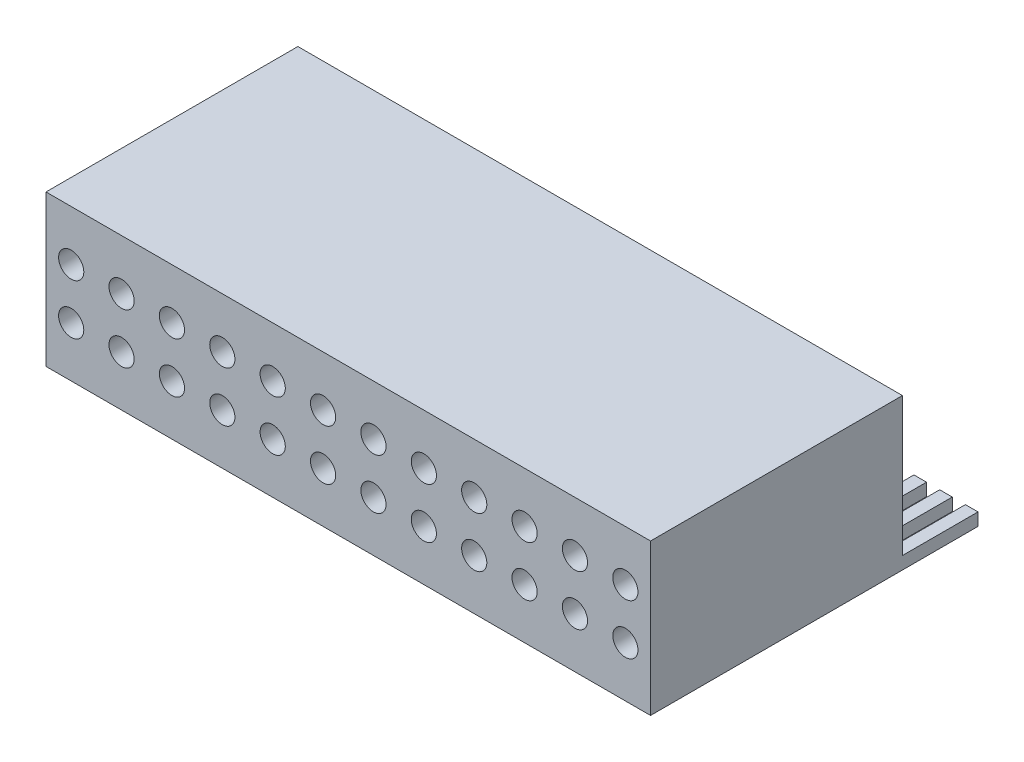
from build123d import *

# Parameters (mm, degrees)
SKETCH2_W           = 24
SKETCH2_H           = 6
BOSS_EXTRUDE1_DEPTH = 10
SKETCH3_R           = 0.5
CUT_EXTRUDE1_DEPTH  = 5
SKETCH4_W           = 0.5
SKETCH4_H           = 3
BOSS_EXTRUDE2_DEPTH = 0.5


with BuildPart() as part:
    # Sketch2 → Boss-Extrude1 (new body)
    with BuildSketch(Plane.XY):
        with Locations((12, 3)):
            Rectangle(SKETCH2_W, SKETCH2_H)
    extrude(amount=BOSS_EXTRUDE1_DEPTH)

    # Sketch3 → Cut-Extrude1 (cut)
    with BuildSketch(Plane.XY.offset(10)):
        with Locations((1, 2)):
            Circle(SKETCH3_R)
        with Locations((3, 2)):
            Circle(SKETCH3_R)
        with Locations((5, 2)):
            Circle(SKETCH3_R)
        with Locations((7, 2)):
            Circle(SKETCH3_R)
        with Locations((9, 2)):
            Circle(SKETCH3_R)
        with Locations((11, 2)):
            Circle(SKETCH3_R)
        with Locations((13, 2)):
            Circle(SKETCH3_R)
        with Locations((15, 2)):
            Circle(SKETCH3_R)
        with Locations((17, 2)):
            Circle(SKETCH3_R)
        with Locations((19, 2)):
            Circle(SKETCH3_R)
        with Locations((21, 2)):
            Circle(SKETCH3_R)
        with Locations((23, 2)):
            Circle(SKETCH3_R)
        with Locations((23, 4)):
            Circle(SKETCH3_R)
        with Locations((21, 4)):
            Circle(SKETCH3_R)
        with Locations((19, 4)):
            Circle(SKETCH3_R)
        with Locations((17, 4)):
            Circle(SKETCH3_R)
        with Locations((15, 4)):
            Circle(SKETCH3_R)
        with Locations((13, 4)):
            Circle(SKETCH3_R)
        with Locations((11, 4)):
            Circle(SKETCH3_R)
        with Locations((9, 4)):
            Circle(SKETCH3_R)
        with Locations((7, 4)):
            Circle(SKETCH3_R)
        with Locations((5, 4)):
            Circle(SKETCH3_R)
        with Locations((3, 4)):
            Circle(SKETCH3_R)
        with Locations((1, 4)):
            Circle(SKETCH3_R)
    extrude(amount=-CUT_EXTRUDE1_DEPTH, mode=Mode.SUBTRACT)

    # Sketch4 → Boss-Extrude2 (add)
    with BuildSketch(Plane(origin=(0, 0, 0), x_dir=(-1, 0, 0), z_dir=(0, -1, 0))):
        with Locations((-0.25, 1.5)):
            Rectangle(SKETCH4_W, SKETCH4_H)
        with Locations((-1.27173914, 1.5)):
            Rectangle(SKETCH4_W, SKETCH4_H)
        with Locations((-2.29347828, 1.5)):
            Rectangle(SKETCH4_W, SKETCH4_H)
        with Locations((-3.31521742, 1.5)):
            Rectangle(SKETCH4_W, SKETCH4_H)
        with Locations((-4.33695656, 1.5)):
            Rectangle(SKETCH4_W, SKETCH4_H)
        with Locations((-5.3586957, 1.5)):
            Rectangle(SKETCH4_W, SKETCH4_H)
        with Locations((-6.38043484, 1.5)):
            Rectangle(SKETCH4_W, SKETCH4_H)
        with Locations((-7.40217398, 1.5)):
            Rectangle(SKETCH4_W, SKETCH4_H)
        with Locations((-8.42391312, 1.5)):
            Rectangle(SKETCH4_W, SKETCH4_H)
        with Locations((-9.44565226, 1.5)):
            Rectangle(SKETCH4_W, SKETCH4_H)
        with Locations((-10.4673914, 1.5)):
            Rectangle(SKETCH4_W, SKETCH4_H)
        with Locations((-11.48913054, 1.5)):
            Rectangle(SKETCH4_W, SKETCH4_H)
        with Locations((-12.51086968, 1.5)):
            Rectangle(SKETCH4_W, SKETCH4_H)
        with Locations((-13.53260882, 1.5)):
            Rectangle(SKETCH4_W, SKETCH4_H)
        with Locations((-14.55434796, 1.5)):
            Rectangle(SKETCH4_W, SKETCH4_H)
        with Locations((-15.5760871, 1.5)):
            Rectangle(SKETCH4_W, SKETCH4_H)
        with Locations((-16.59782624, 1.5)):
            Rectangle(SKETCH4_W, SKETCH4_H)
        with Locations((-17.61956538, 1.5)):
            Rectangle(SKETCH4_W, SKETCH4_H)
        with Locations((-18.64130452, 1.5)):
            Rectangle(SKETCH4_W, SKETCH4_H)
        with Locations((-19.66304366, 1.5)):
            Rectangle(SKETCH4_W, SKETCH4_H)
        with Locations((-20.6847828, 1.5)):
            Rectangle(SKETCH4_W, SKETCH4_H)
        with Locations((-21.70652194, 1.5)):
            Rectangle(SKETCH4_W, SKETCH4_H)
        with Locations((-22.72826108, 1.5)):
            Rectangle(SKETCH4_W, SKETCH4_H)
        with Locations((-23.75000022, 1.5)):
            Rectangle(SKETCH4_W, SKETCH4_H)
    extrude(amount=-BOSS_EXTRUDE2_DEPTH)


solid = part.part
